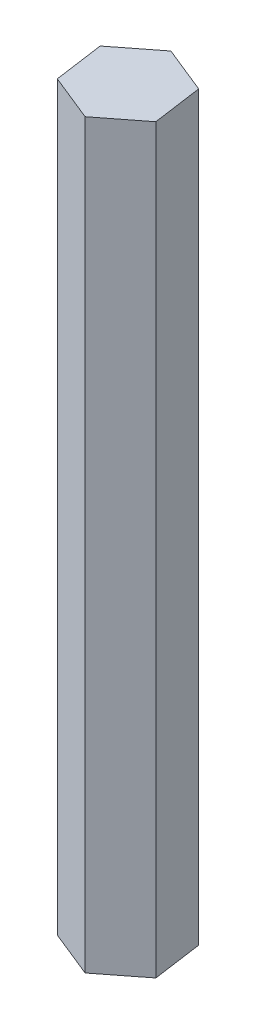
from build123d import *

# Parameters (mm, degrees)
BOSS_EXTRUDE1_DEPTH = 107.95


with BuildPart() as part:
    # Sketch1 → Boss-Extrude1 (new body)
    with BuildSketch(Plane(origin=(0, 0, 0), x_dir=(1, 0, 0), z_dir=(0, 1, 0))):
        Polygon((5.778708696, 4.513298033), (-1.019276403, 7.261157549), (-6.7979851, 2.747859516), (-5.778708696, -4.513298033), (1.019276403, -7.261157549), (6.7979851, -2.747859516), align=None)
    extrude(amount=BOSS_EXTRUDE1_DEPTH)


solid = part.part
